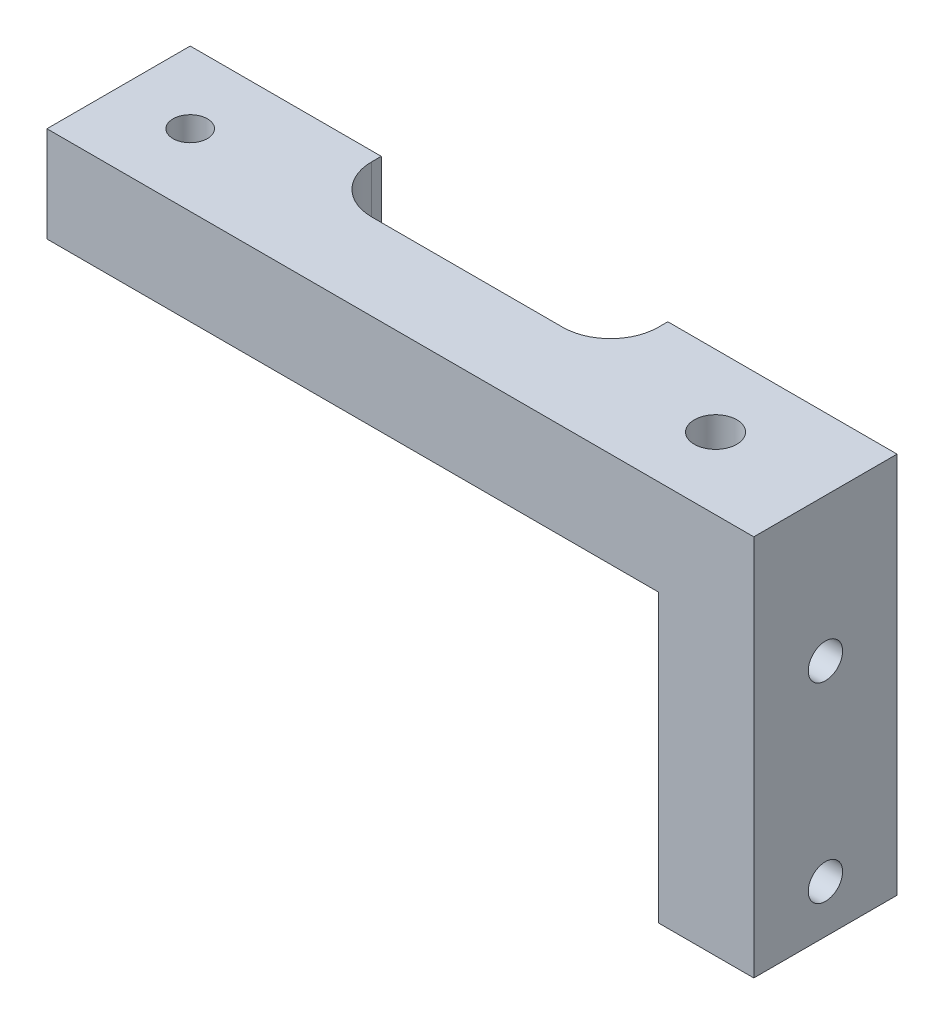
from build123d import *

# Parameters (mm, degrees)
SKETCH3_W           = 44.45
SKETCH3_H           = 25.4
BOSS_EXTRUDE2_DEPTH = 9.525
SKETCH4_W           = 34.925
SKETCH4_H           = 15.875
CUT_EXTRUDE1_DEPTH  = 10.525
SKETCH5_R           = 1.143
CUT_EXTRUDE2_DEPTH  = 9.525
SKETCH6_W           = 34.925
SKETCH6_H           = 9.525
CUT_EXTRUDE3_DEPTH  = 3.175
SKETCH7_W           = 19.05
SKETCH7_H           = 3.81
CUT_EXTRUDE4_DEPTH  = 26.4
FILLET1_R           = 3.175
SKETCH8_R           = 1.143
SKETCH8_R_2         = 1.41354867
CUT_EXTRUDE5_DEPTH  = 9.525
SKETCH9_W           = 9.525
SKETCH9_H           = 25.4
SKETCH9_R           = 1.143
BOSS_EXTRUDE3_DEPTH = 2.54
SKETCH10_W          = 9.525
SKETCH10_H          = 19.05
SKETCH10_R          = 1.143
CUT_EXTRUDE6_DEPTH  = 5.715


with BuildPart() as part:
    # Sketch3 → Boss-Extrude2 (new body)
    with BuildSketch(Plane.XY):
        with Locations((-22.225, 12.7)):
            Rectangle(SKETCH3_W, SKETCH3_H)
    extrude(amount=BOSS_EXTRUDE2_DEPTH)

    # Sketch4 → Cut-Extrude1 (cut, through all)
    with BuildSketch(Plane.XY.offset(9.525)):
        with Locations((-26.9875, 7.9375)):
            Rectangle(SKETCH4_W, SKETCH4_H)
    extrude(amount=-CUT_EXTRUDE1_DEPTH, mode=Mode.SUBTRACT)

    # Sketch5 → Cut-Extrude2 (cut)
    with BuildSketch(Plane(origin=(0, 0, 0), x_dir=(0, 0, -1), z_dir=(1, 0, 0))):
        with Locations((-4.7625, 3.175)):
            Circle(SKETCH5_R)
        with Locations((-4.7625, 15.875)):
            Circle(SKETCH5_R)
    extrude(amount=-CUT_EXTRUDE2_DEPTH, mode=Mode.SUBTRACT)

    # Sketch6 → Cut-Extrude3 (cut)
    with BuildSketch(Plane.XZ.offset(-15.875)):
        with Locations((-26.9875, 4.7625)):
            Rectangle(SKETCH6_W, SKETCH6_H)
    extrude(amount=-CUT_EXTRUDE3_DEPTH, mode=Mode.SUBTRACT)

    # Sketch7 → Cut-Extrude4 (cut, through all)
    with BuildSketch(Plane(origin=(0, 25.4, 0), x_dir=(1, 0, 0), z_dir=(0, 1, 0))):
        with Locations((-22.225, -1.905)):
            Rectangle(SKETCH7_W, SKETCH7_H)
    extrude(amount=-CUT_EXTRUDE4_DEPTH, mode=Mode.SUBTRACT)

    # Fillet1
    fillet1_edges = [part.edges().sort_by_distance(p)[0] for p in [
        (-12.7, 22.225, 3.81),
        (-31.75, 22.225, 3.81),
    ]]
    fillet(fillet1_edges, radius=FILLET1_R)

    # Sketch8 → Cut-Extrude5 (cut)
    with BuildSketch(Plane(origin=(0, 25.4, 0), x_dir=(1, 0, 0), z_dir=(0, 1, 0))):
        with Locations((-39.6875, -4.7625)):
            Circle(SKETCH8_R)
        with Locations((-4.7625, -4.7625)):
            Circle(SKETCH8_R_2)
    extrude(amount=-CUT_EXTRUDE5_DEPTH, mode=Mode.SUBTRACT)

    # Sketch9 → Boss-Extrude3 (add)
    with BuildSketch(Plane(origin=(0, 0, 0), x_dir=(0, 0, -1), z_dir=(1, 0, 0))):
        with Locations((-4.7625, 12.7)):
            Rectangle(SKETCH9_W, SKETCH9_H)
        with Locations((-4.7625, 15.875)):
            Circle(SKETCH9_R, mode=Mode.SUBTRACT)
        with Locations((-4.7625, 3.175)):
            Circle(SKETCH9_R, mode=Mode.SUBTRACT)
    extrude(amount=BOSS_EXTRUDE3_DEPTH)

    # Sketch10 → Cut-Extrude6 (cut)
    with BuildSketch(Plane.ZY.offset(9.525)):
        with Locations((4.7625, 9.525)):
            Rectangle(SKETCH10_W, SKETCH10_H)
        with Locations((4.7625, 15.875)):
            Circle(SKETCH10_R, mode=Mode.SUBTRACT)
        with Locations((4.7625, 3.175)):
            Circle(SKETCH10_R, mode=Mode.SUBTRACT)
    extrude(amount=-CUT_EXTRUDE6_DEPTH, mode=Mode.SUBTRACT)


solid = part.part
